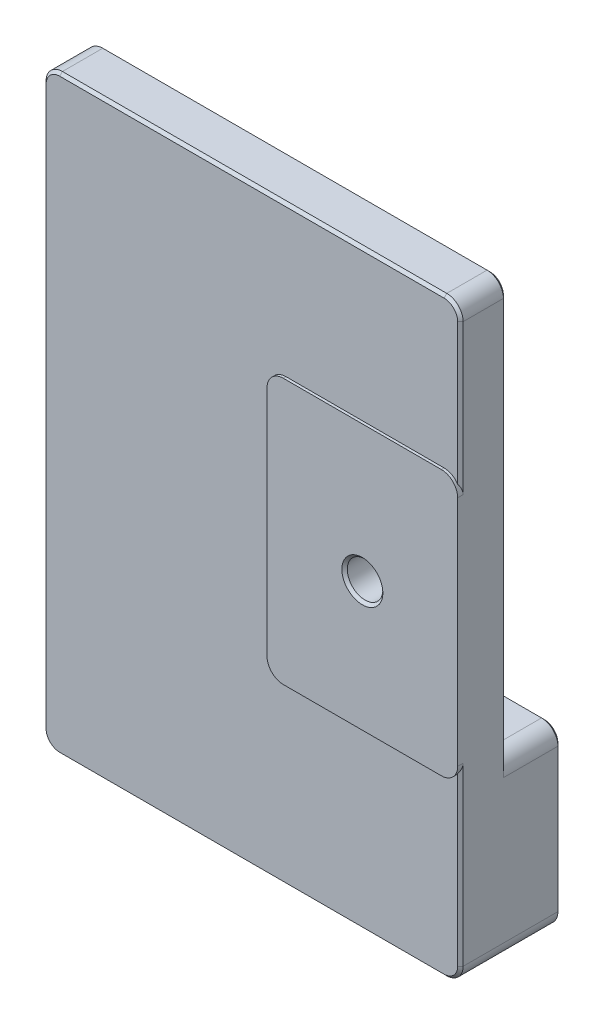
from build123d import *

# Parameters (mm, degrees)
SKETCH1_W           = 76.560291348
SKETCH1_H           = 108.5
SKETCH1_R           = 3.2639
BOSS_EXTRUDE1_DEPTH = 8.4
SKETCH1_3_W         = 35
SKETCH1_3_H         = 48.7
SKETCH1_3_R         = 3.2639
BOSS_EXTRUDE2_DEPTH = 8.9
SKETCH1_4_W         = 76.560291348
SKETCH1_4_H         = 32.3
BOSS_EXTRUDE3_DEPTH = 10
FILLET1_R           = 3
CHAMFER1_SIZE       = 0.5


with BuildPart() as part:
    # Sketch1 → Boss-Extrude1 (new body)
    with BuildSketch(Plane.XY):
        with Locations((83.619854326, -16.15)):
            Rectangle(SKETCH1_W, SKETCH1_H)
        with Locations((104.4, -14.4)):
            Circle(SKETCH1_R, mode=Mode.SUBTRACT)
    extrude(amount=BOSS_EXTRUDE1_DEPTH)

    # Sketch1_3 → Boss-Extrude2 (add)
    with BuildSketch(Plane.XY):
        with Locations((104.4, -13.75)):
            Rectangle(SKETCH1_3_W, SKETCH1_3_H)
        with Locations((104.4, -14.4)):
            Circle(SKETCH1_3_R, mode=Mode.SUBTRACT)
    extrude(amount=BOSS_EXTRUDE2_DEPTH)

    # Sketch1_4 → Boss-Extrude3 (add)
    with BuildSketch(Plane.XY):
        with Locations((83.619854326, -54.25)):
            Rectangle(SKETCH1_4_W, SKETCH1_4_H)
    extrude(amount=-BOSS_EXTRUDE3_DEPTH)

    # Fillet1
    fillet1_edges = [part.edges().sort_by_distance(p)[0] for p in [
        (45.339708652, 38.1, 4.2),
        (121.9, -38.1, 8.65),
        (86.9, -38.1, 8.65),
        (86.9, 10.6, 8.65),
        (121.9, 10.6, 8.65),
        (45.339708652, -70.4, -0.8),
        (121.9, -38.1, -5),
        (45.339708652, -38.1, -5),
        (121.9, -70.4, -0.8),
        (121.9, 38.1, 4.2),
    ]]
    fillet(fillet1_edges, radius=FILLET1_R)

    # Chamfer1
    chamfer1_edges = [part.edges().sort_by_distance(p)[0] for p in [
        (121.9, 22.85, 8.4),
        (101.1361, -14.4, 8.9),
        (101.1361, -14.4, 0),
        (121.9, -54.25, -10),
        (121.9, -1.5, 0),
        (121.9, -52.75, 8.4),
        (45.339708652, -16.15, 8.4),
        (45.339708652, -1.5, 0),
        (45.339708652, -54.25, -10),
        (83.619854326, 38.1, 0),
        (121.021320344, 37.221320344, 0),
        (46.218388308, 37.221320344, 0),
        (83.619854326, 38.1, 8.4),
        (83.619854326, -70.4, 8.4),
        (121.021320344, -69.521320344, 8.4),
        (46.218388308, -69.521320344, 8.4),
        (121.021320344, 37.221320344, 8.4),
        (46.218388308, 37.221320344, 8.4),
        (83.619854326, -38.1, -10),
        (83.619854326, -70.4, -10),
        (121.021320344, -69.521320344, -10),
        (46.218388308, -69.521320344, -10),
        (121.021320344, -38.978679656, -10),
        (46.218388308, -38.978679656, -10),
    ]]
    chamfer(chamfer1_edges, length=CHAMFER1_SIZE)


solid = part.part
